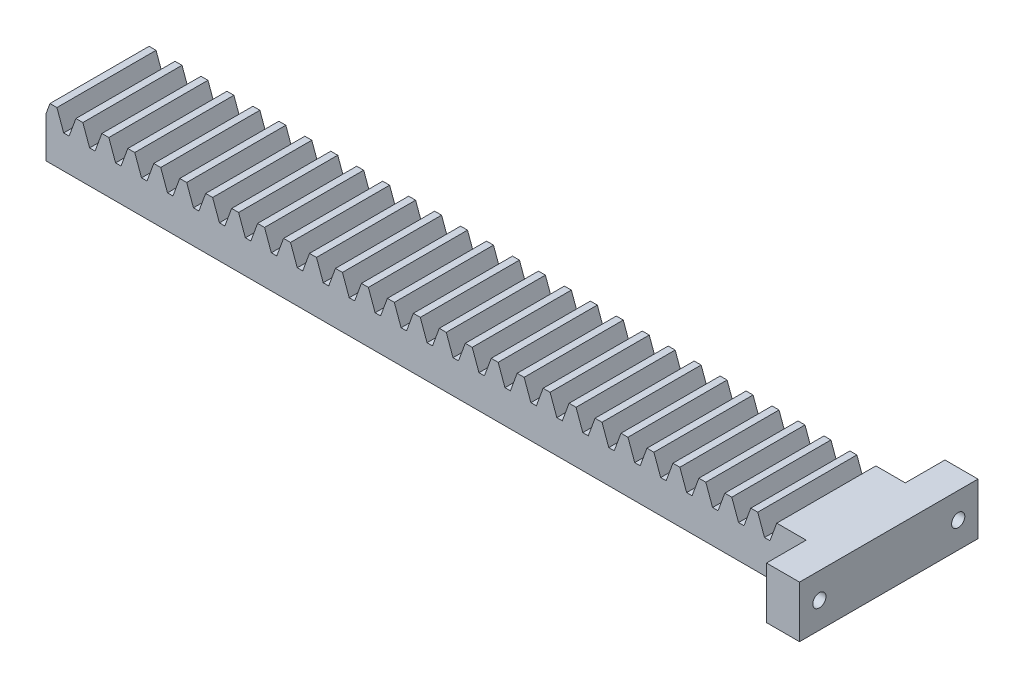
from build123d import *

# Parameters (mm, degrees)
BOSS_EXTRUDE1_DEPTH = 15
SKETCH1_3_W         = 10
SKETCH1_3_H         = 15.625
BOSS_EXTRUDE2_DEPTH = 27
SKETCH2_R           = 2
CUT_EXTRUDE1_DEPTH  = 54


with BuildPart() as part:
    # Sketch1 → Boss-Extrude1 (new, symmetric)
    with BuildSketch(Plane.XY):
        Polygon((110, -7.8125), (110, 7.8125), (101.101563673, 7.8125), (99.054231105, 2.1875), (97.402035886, 2.1875), (95.354703318, 7.8125), (93.247563673, 7.8125), (91.200231105, 2.1875), (89.548035886, 2.1875), (87.500703318, 7.8125), (85.393563673, 7.8125), (83.346231105, 2.1875), (81.694035886, 2.1875), (79.646703318, 7.8125), (77.539563673, 7.8125), (75.492231105, 2.1875), (73.840035886, 2.1875), (71.792703318, 7.8125), (69.685563673, 7.8125), (67.638231105, 2.1875), (65.986035886, 2.1875), (63.938703318, 7.8125), (61.831563673, 7.8125), (59.784231105, 2.1875), (58.132035886, 2.1875), (56.084703318, 7.8125), (53.977563673, 7.8125), (51.930231105, 2.1875), (50.278035886, 2.1875), (48.230703318, 7.8125), (46.123563673, 7.8125), (44.076231105, 2.1875), (42.424035886, 2.1875), (40.376703318, 7.8125), (38.269563673, 7.8125), (36.222231105, 2.1875), (34.570035886, 2.1875), (32.522703318, 7.8125), (30.415563673, 7.8125), (28.368231105, 2.1875), (26.716035886, 2.1875), (24.668703318, 7.8125), (22.561563673, 7.8125), (20.514231105, 2.1875), (18.862035886, 2.1875), (16.814703318, 7.8125), (14.707563673, 7.8125), (12.660231105, 2.1875), (11.008035886, 2.1875), (8.960703318, 7.8125), (6.853563673, 7.8125), (4.806231105, 2.1875), (3.154035886, 2.1875), (1.106703318, 7.8125), (-1.000436327, 7.8125), (-3.047768895, 2.1875), (-4.699964114, 2.1875), (-6.747296682, 7.8125), (-8.854436327, 7.8125), (-10.901768895, 2.1875), (-12.553964114, 2.1875), (-14.601296682, 7.8125), (-16.708436327, 7.8125), (-18.755768895, 2.1875), (-20.407964114, 2.1875), (-22.455296682, 7.8125), (-24.562436327, 7.8125), (-26.609768895, 2.1875), (-28.261964114, 2.1875), (-30.309296682, 7.8125), (-32.416436327, 7.8125), (-34.463768895, 2.1875), (-36.115964114, 2.1875), (-38.163296682, 7.8125), (-40.270436327, 7.8125), (-42.317768895, 2.1875), (-43.969964114, 2.1875), (-46.017296682, 7.8125), (-48.124436327, 7.8125), (-50.171768895, 2.1875), (-51.823964114, 2.1875), (-53.871296682, 7.8125), (-55.978436327, 7.8125), (-58.025768895, 2.1875), (-59.677964114, 2.1875), (-61.725296682, 7.8125), (-63.832436327, 7.8125), (-65.879768895, 2.1875), (-67.531964114, 2.1875), (-69.579296682, 7.8125), (-71.686436327, 7.8125), (-73.733768895, 2.1875), (-75.385964114, 2.1875), (-77.433296682, 7.8125), (-79.540436327, 7.8125), (-81.587768895, 2.1875), (-83.239964114, 2.1875), (-85.287296682, 7.8125), (-87.394436327, 7.8125), (-89.441768895, 2.1875), (-91.093964114, 2.1875), (-93.141296682, 7.8125), (-95.248436327, 7.8125), (-97.295768895, 2.1875), (-98.947964114, 2.1875), (-100.995296682, 7.8125), (-103.102436327, 7.8125), (-105.149768895, 2.1875), (-106.801964114, 2.1875), (-108.849296682, 7.8125), (-110.956436327, 7.8125), (-113.003768895, 2.1875), (-114.655964114, 2.1875), (-116.703296682, 7.8125), (-118.810436327, 7.8125), (-120, 4.54420067), (-120, -7.8125), align=None)
    extrude(amount=BOSS_EXTRUDE1_DEPTH, both=True)

    # Sketch1_3 → Boss-Extrude2 (add, symmetric)
    with BuildSketch(Plane.XY):
        with Locations((115, 0)):
            Rectangle(SKETCH1_3_W, SKETCH1_3_H)
    extrude(amount=BOSS_EXTRUDE2_DEPTH, both=True)

    # Sketch2 → Cut-Extrude1 (cut)
    with BuildSketch(Plane(origin=(120, 0, 0), x_dir=(0, 0, -1), z_dir=(1, 0, 0))):
        with Locations((21.012499646, 0.042849803)):
            Circle(SKETCH2_R)
        with Locations((-21.002491739, 0.042849803)):
            Circle(SKETCH2_R)
    extrude(amount=-CUT_EXTRUDE1_DEPTH, mode=Mode.SUBTRACT)


solid = part.part
